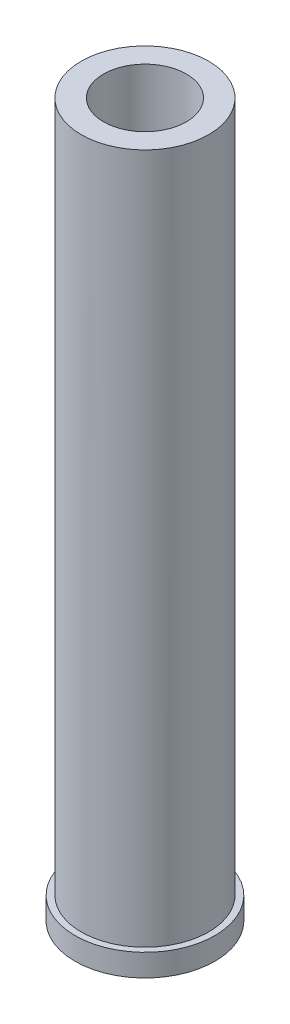
from build123d import *

# Parameters (mm, degrees)
SKETCH1_R           = 14.3
SKETCH1_R_2         = 9.3
BOSS_EXTRUDE1_DEPTH = 160
SKETCH2_W           = 1.4
SKETCH2_H           = 5


with BuildPart() as part:
    # Sketch1 → Boss-Extrude1 (new body)
    with BuildSketch(Plane(origin=(0, 0, 0), x_dir=(1, 0, 0), z_dir=(0, 1, 0))):
        Circle(SKETCH1_R)
        Circle(SKETCH1_R_2, mode=Mode.SUBTRACT)
    extrude(amount=BOSS_EXTRUDE1_DEPTH)

    # Sketch2 → Revolve3 (revolve)
    with BuildSketch(Plane.XY):
        with Locations((-15, 2.5)):
            Rectangle(SKETCH2_W, SKETCH2_H)
    revolve(axis=Axis((0, 300, 0), (0, -1, 0)))


solid = part.part
